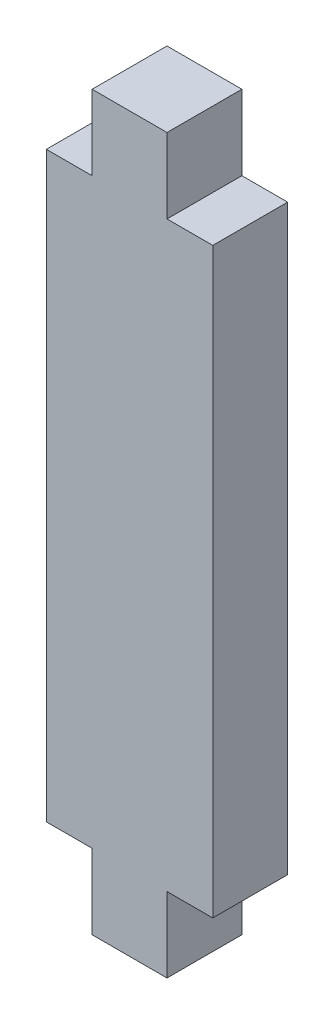
from build123d import *

# Parameters (mm, degrees)
SKETCH2_W           = 4.5
SKETCH2_H           = 4.5
SKETCH2_W_2         = 10
SKETCH2_H_2         = 17.5
BOSS_EXTRUDE1_DEPTH = 2.25


with BuildPart() as part:
    # Sketch2 → Boss-Extrude1 (new body, symmetric)
    with BuildSketch(Plane.XY):
        with Locations((0, 19.75)):
            Rectangle(SKETCH2_W, SKETCH2_H)
        with Locations((0, 8.75)):
            Rectangle(SKETCH2_W_2, SKETCH2_H_2)
    extrude(amount=BOSS_EXTRUDE1_DEPTH, both=True)

    # Mirror1: part across plane


with BuildPart() as part_1:
    add(part.part)
    add(part.part.mirror(Plane.ZX))


solid = part_1.part
